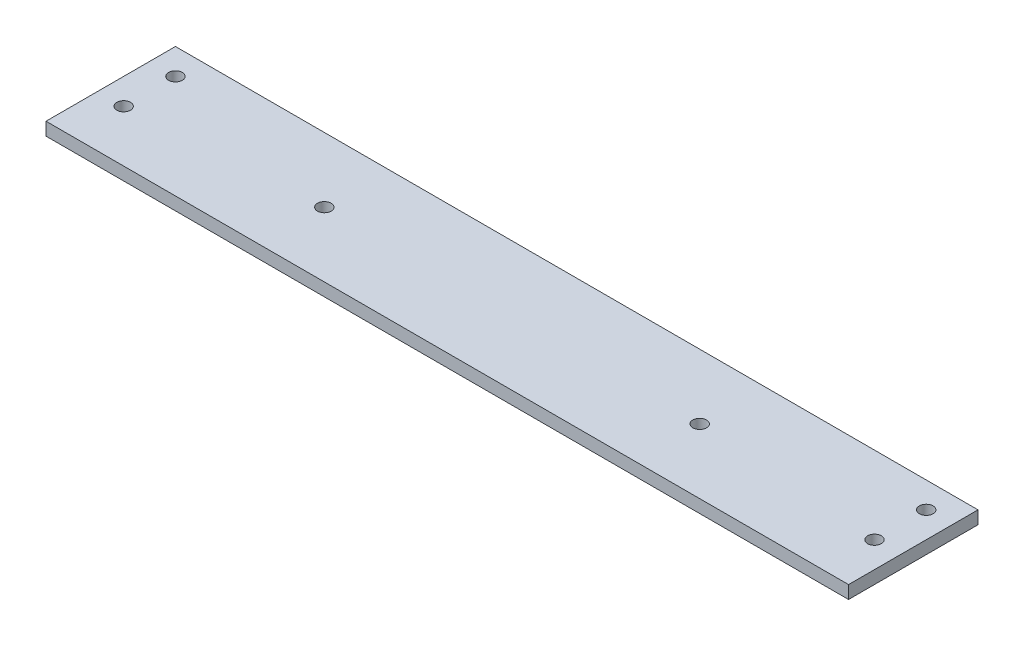
from build123d import *

# Parameters (mm, degrees)
SKETCH1_W           = 393.7
SKETCH1_H           = 63.5
BOSS_EXTRUDE1_DEPTH = 6.35
SKETCH2_R           = 3.3655
SKETCH2_R_2         = 2.5527
CUT_EXTRUDE1_DEPTH  = 200.49513152


with BuildPart() as part:
    # Sketch1 → Boss-Extrude1 (new body)
    with BuildSketch(Plane(origin=(0, 0, 0), x_dir=(1, 0, 0), z_dir=(0, 1, 0))):
        Rectangle(SKETCH1_W, SKETCH1_H)
    extrude(amount=BOSS_EXTRUDE1_DEPTH)

    # Sketch2 → Cut-Extrude1 (cut, through all)
    with BuildSketch(Plane.XZ):
        with Locations(Location((-92.062267829, 0, 0), (0, 0, 270))):
            Circle(SKETCH2_R)
        with Locations((-92.062267829, 0)):
            Circle(SKETCH2_R_2, mode=Mode.SUBTRACT)
        with Locations((-92.062267829, 0)):
            Circle(SKETCH2_R_2)
        with Locations(Location((-184.15, 6.35, 0), (0, 0, 270))):
            Circle(SKETCH2_R)
        with Locations(Location((-184.15, -19.05, 0), (0, 0, 270))):
            Circle(SKETCH2_R)
        with Locations(Location((92.075, 0, 0), (0, 0, 270))):
            Circle(SKETCH2_R)
        with Locations((92.075, 0)):
            Circle(SKETCH2_R_2, mode=Mode.SUBTRACT)
        with Locations((92.075, 0)):
            Circle(SKETCH2_R_2)
        with Locations(Location((184.15, 6.35, 0), (0, 0, 270))):
            Circle(SKETCH2_R)
        with Locations(Location((184.15, -19.05, 0), (0, 0, 270))):
            Circle(SKETCH2_R)
    extrude(amount=-CUT_EXTRUDE1_DEPTH, mode=Mode.SUBTRACT)


solid = part.part
